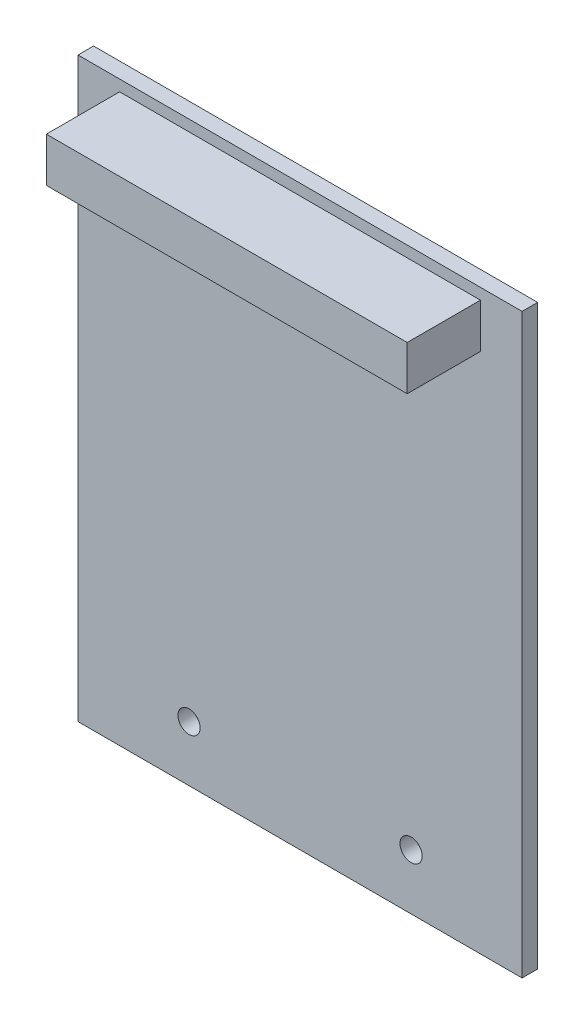
from build123d import *

# Parameters (mm, degrees)
SKETCH1_W           = 50.8
SKETCH1_H           = 66.04
BOSS_EXTRUDE1_DEPTH = 1.778
SKETCH2_W           = 41.275
SKETCH2_H           = 5.08
BOSS_EXTRUDE2_DEPTH = 8.382
SKETCH3_R           = 1.27
CUT_EXTRUDE1_DEPTH  = 1.778


with BuildPart() as part:
    # Sketch1 → Boss-Extrude1 (new body)
    with BuildSketch(Plane.XY):
        with Locations((25.4, 33.02)):
            Rectangle(SKETCH1_W, SKETCH1_H)
    extrude(amount=BOSS_EXTRUDE1_DEPTH)

    # Sketch2 → Boss-Extrude2 (add)
    with BuildSketch(Plane.XY.offset(1.778)):
        with Locations((25.4, 62.23)):
            Rectangle(SKETCH2_W, SKETCH2_H)
    extrude(amount=BOSS_EXTRUDE2_DEPTH)

    # Sketch3 → Cut-Extrude1 (cut)
    with BuildSketch(Plane.XY.offset(1.778)):
        with Locations((12.7, 6.35)):
            Circle(SKETCH3_R)
        with Locations((38.1, 6.35)):
            Circle(SKETCH3_R)
    extrude(amount=-CUT_EXTRUDE1_DEPTH, mode=Mode.SUBTRACT)


solid = part.part
